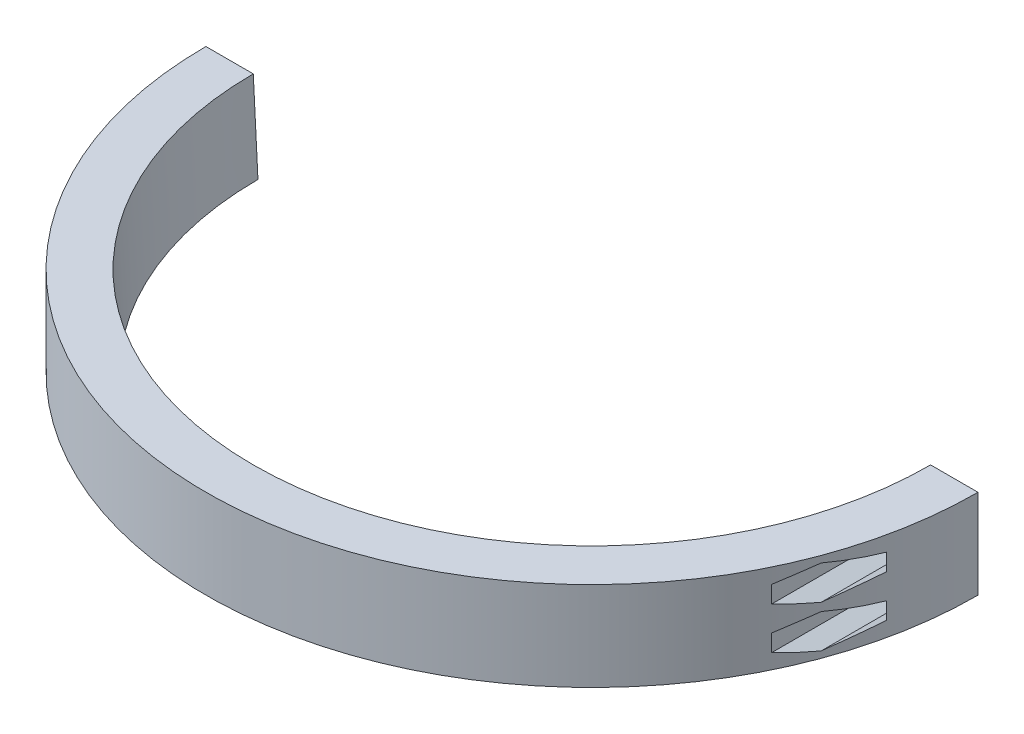
from build123d import *

# Parameters (mm, degrees)
REVOLVE2_ANGLE        = 180
CUT_EXTRUDE1_DEPTH    = 50
F_2_0MM_DOWEL_HOLE1_D = 2.3
SKETCH13_R            = 1.65
CUT_EXTRUDE2_DEPTH    = 100


with BuildPart() as part:
    # Sketch3 → Revolve2 (revolve)
    with BuildSketch(Plane.XY):
        Polygon((48.25, 0), (47.584421203, -12.7), (55, -12.7), (55, 0), align=None)
    revolve(axis=Axis((0, 50.355486862, 0), (0, -1, 0)), revolution_arc=REVOLVE2_ANGLE)

    # Sketch9 → Cut-Extrude1 (cut)
    with BuildSketch(Plane.XY.offset(55)):
        Polygon((53.725, -4.562435565), (53.725, -2.137564435), (51.625, -0.925128869), (49.525, -2.137564435), (49.525, -4.562435565), (51.625, -5.774871131), align=None)
        Polygon((53.725, -10.562435565), (53.725, -8.137564435), (51.625, -6.925128869), (49.525, -8.137564435), (49.525, -10.562435565), (51.625, -11.774871131), align=None)
    cut_extrude1 = extrude(amount=-CUT_EXTRUDE1_DEPTH, mode=Mode.SUBTRACT)

    # Ø2.0mm Dowel Hole1 (through all)
    with Locations(Plane.XY.offset(5)):
        with Locations((51.625, -9.35), (51.625, -3.35)):
            f_2_0mm_dowel_hole1 = Hole(F_2_0MM_DOWEL_HOLE1_D / 2)

    # Mirror2: Cut-Extrude1, Ø2.0mm Dowel Hole1 across plane
    add(cut_extrude1.mirror(Plane(origin=(0, 0, 0), x_dir=(0, 0, 1), z_dir=(1, 0, 0))), mode=Mode.SUBTRACT)
    add(f_2_0mm_dowel_hole1.mirror(Plane(origin=(0, 0, 0), x_dir=(0, 0, 1), z_dir=(1, 0, 0))), mode=Mode.SUBTRACT)

    # Sketch13 → Cut-Extrude2 (cut, symmetric)
    with BuildSketch(Plane(origin=(0, 0, 0), x_dir=(0.707106781, 0, 0.707106781), z_dir=(-0.707106781, 0, 0.707106781))):
        with Locations((0, -6.35)):
            Circle(SKETCH13_R)
    extrude(amount=CUT_EXTRUDE2_DEPTH, both=True, mode=Mode.SUBTRACT)


solid = part.part
